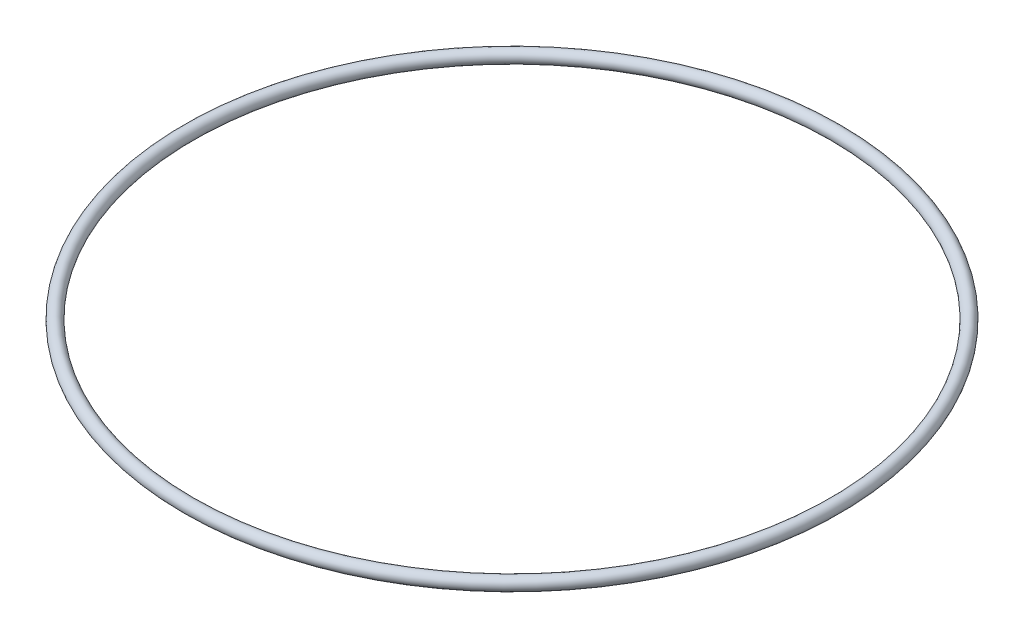
from build123d import *

# Parameters (mm, degrees)
SKETCH1_R = 0.8255


with BuildPart() as part:
    # Sketch1 → Revolve1 (revolve)
    with BuildSketch(Plane.XY):
        with Locations((-41.91, 0)):
            Circle(SKETCH1_R)
    revolve(axis=Axis((0, 0, 0), (0, 1, 0)))


solid = part.part
